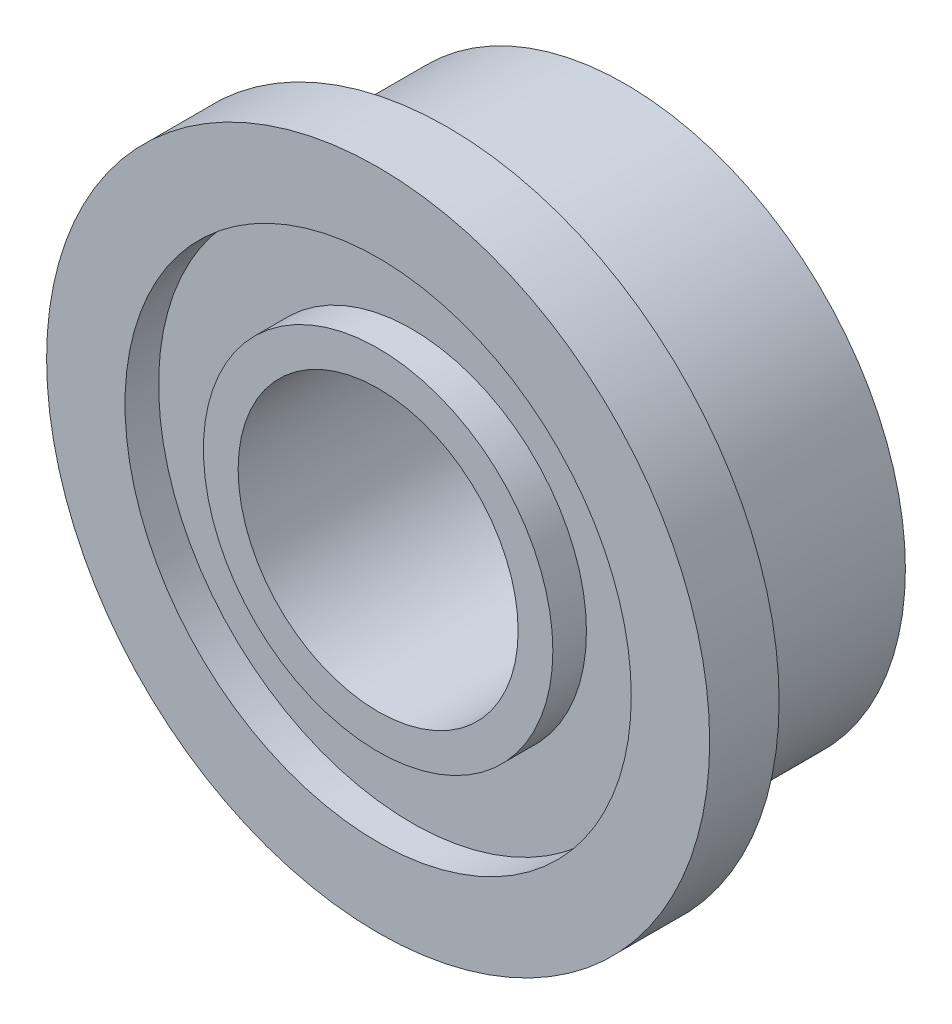
from build123d import *

# Parameters (mm, degrees)
SKETCH1_R           = 3.175
SKETCH1_R_2         = 1.5875
BOSS_EXTRUDE1_DEPTH = 2.016125
SKETCH2_R           = 3.7592
SKETCH2_R_2         = 1.5875
BOSS_EXTRUDE2_DEPTH = 0.7874
SKETCH3_R           = 2.8702
SKETCH3_R_2         = 1.9812
CUT_EXTRUDE1_DEPTH  = 0.381


with BuildPart() as part:
    # Sketch1 → Boss-Extrude1 (new body)
    with BuildSketch(Plane.XY):
        Circle(SKETCH1_R)
        Circle(SKETCH1_R_2, mode=Mode.SUBTRACT)
    extrude(amount=BOSS_EXTRUDE1_DEPTH)

    # Sketch2 → Boss-Extrude2 (add)
    with BuildSketch(Plane.XY.offset(2.016125)):
        Circle(SKETCH2_R)
        Circle(SKETCH2_R_2, mode=Mode.SUBTRACT)
    extrude(amount=BOSS_EXTRUDE2_DEPTH)

    # Sketch3 → Cut-Extrude1 (cut)
    with BuildSketch(Plane.XY.offset(2.803525)):
        Circle(SKETCH3_R)
        Circle(SKETCH3_R_2, mode=Mode.SUBTRACT)
    extrude(amount=-CUT_EXTRUDE1_DEPTH, mode=Mode.SUBTRACT)


solid = part.part
